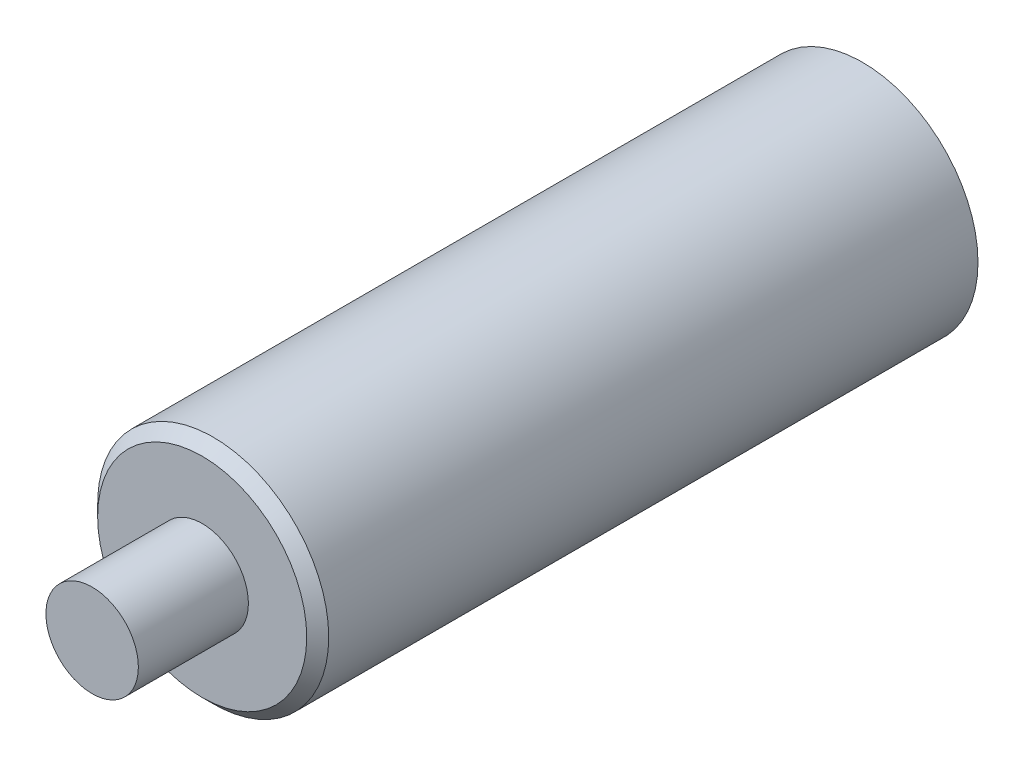
from build123d import *

# Parameters (mm, degrees)
ESQUISSE1_R                  = 5.25
BOSS_EXTRU_1_DEPTH           = 30
CHANFREIN1_SIZE              = 0.5
ESQUISSE2_R                  = 1.75
ENL_V_MAT_EXTRU_1_DEPTH      = 1
ENL_V_MAT_EXTRU_1_DEPTH_BACK = 15
ESQUISSE4_R                  = 2.1
BOSS_EXTRU_2_DEPTH           = 5


with BuildPart() as part:
    # Esquisse1 → Boss.-Extru.1 (new body)
    with BuildSketch(Plane.XY):
        Circle(ESQUISSE1_R)
    extrude(amount=BOSS_EXTRU_1_DEPTH)

    # Chanfrein1
    chanfrein1_edges = [part.edges().sort_by_distance(p)[0] for p in [
        (-5.25, 0, 30),
    ]]
    chamfer(chanfrein1_edges, length=CHANFREIN1_SIZE)

    # Esquisse2 → Enlèv. mat.-Extru.1 (cut, two sides)
    with BuildSketch(Plane(origin=(0, 0, 0), x_dir=(-1, 0, 0), z_dir=(0, 0, -1))) as enl_v_mat_extru_1_sk:
        Circle(ESQUISSE2_R)
    extrude(amount=ENL_V_MAT_EXTRU_1_DEPTH, mode=Mode.SUBTRACT)
    extrude(enl_v_mat_extru_1_sk.sketch, amount=-ENL_V_MAT_EXTRU_1_DEPTH_BACK, mode=Mode.SUBTRACT)

    # Esquisse4 → Boss.-Extru.2 (add)
    with BuildSketch(Plane.XY.offset(30)):
        Circle(ESQUISSE4_R)
    extrude(amount=BOSS_EXTRU_2_DEPTH)


solid = part.part
